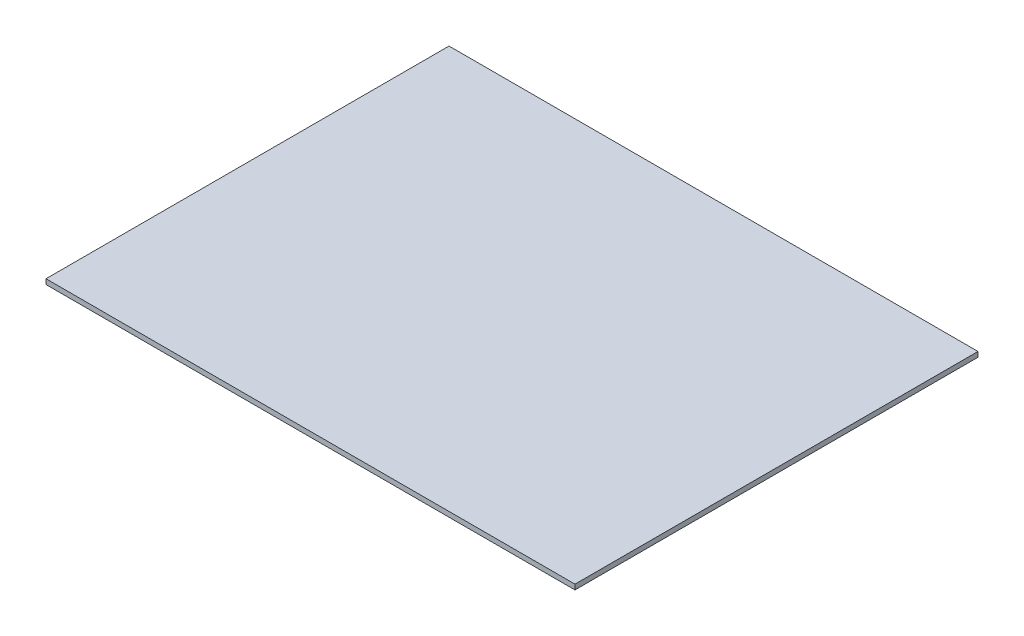
from build123d import *

# Parameters (mm, degrees)
CROQUIS1_W              = 210
CROQUIS1_H              = 160
SALIENTE_EXTRUIR1_DEPTH = 2


with BuildPart() as part:
    # Croquis1 → Saliente-Extruir1 (new body)
    with BuildSketch(Plane(origin=(0, 0, 0), x_dir=(1, 0, 0), z_dir=(0, 1, 0))):
        with Locations((105, 80)):
            Rectangle(CROQUIS1_W, CROQUIS1_H)
    extrude(amount=SALIENTE_EXTRUIR1_DEPTH)


solid = part.part
